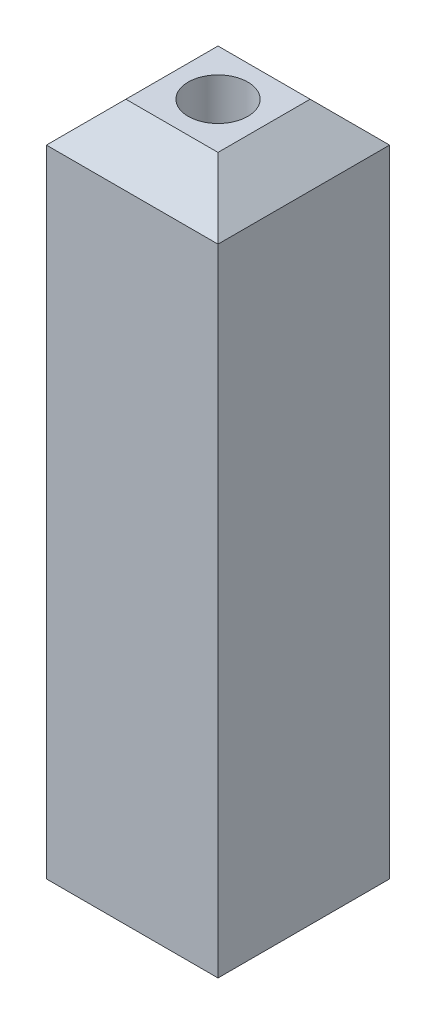
from build123d import *

# Parameters (mm, degrees)
SKETCH1_W                            = 54.864
SKETCH1_H                            = 54.864
BOSS_EXTRUDE2_DEPTH                  = 215.9
F_3_4_0_75_DIAMETER_HOLE1_D          = 19.05
F_3_4_0_75_DIAMETER_HOLE1_DEPTH      = 152.4
F_3_4_0_75_DIAMETER_HOLE1_TIP        = 5.723197396
F_13_64_0_20313_DIAMETER_HOLE1_D     = 5.159502
F_13_64_0_20313_DIAMETER_HOLE1_DEPTH = 152.4
F_13_64_0_20313_DIAMETER_HOLE1_TIP   = 1.550070783
F_3_4_0_75_DIAMETER_HOLE2_D          = 19.05
F_3_4_0_75_DIAMETER_HOLE2_DEPTH      = 42.545
F_3_4_0_75_DIAMETER_HOLE2_TIP        = 5.723197396
CHAMFER1_SIZE                        = 12.7


with BuildPart() as part:
    # Sketch1 → Boss-Extrude2 (new body)
    with BuildSketch(Plane(origin=(0, 0, 0), x_dir=(1, 0, 0), z_dir=(0, 1, 0))):
        Rectangle(SKETCH1_W, SKETCH1_H)
    extrude(amount=BOSS_EXTRUDE2_DEPTH)

    # 3/4 (0.75) Diameter Hole1
    with Locations(Plane.XZ):
        with Locations((0, 0)):
            Hole(F_3_4_0_75_DIAMETER_HOLE1_D / 2, depth=F_3_4_0_75_DIAMETER_HOLE1_DEPTH)
            with Locations((0, 0, -(F_3_4_0_75_DIAMETER_HOLE1_DEPTH + F_3_4_0_75_DIAMETER_HOLE1_TIP / 2))):  # 118° drill point
                Cone(0, F_3_4_0_75_DIAMETER_HOLE1_D / 2, F_3_4_0_75_DIAMETER_HOLE1_TIP, mode=Mode.SUBTRACT)

    # 13/64 (0.20313) Diameter Hole1
    with Locations(Plane.XZ):
        with Locations((-23.622, 23.622), (23.622, 23.622), (23.622, -23.622), (-23.622, -23.622)):
            Hole(F_13_64_0_20313_DIAMETER_HOLE1_D / 2, depth=F_13_64_0_20313_DIAMETER_HOLE1_DEPTH)
            with Locations((0, 0, -(F_13_64_0_20313_DIAMETER_HOLE1_DEPTH + F_13_64_0_20313_DIAMETER_HOLE1_TIP / 2))):  # 118° drill point
                Cone(0, F_13_64_0_20313_DIAMETER_HOLE1_D / 2, F_13_64_0_20313_DIAMETER_HOLE1_TIP, mode=Mode.SUBTRACT)

    # 3/4 (0.75) Diameter Hole2
    with Locations(Plane(origin=(0, 215.9, 0), x_dir=(-1, 0, 0), z_dir=(0, 1, 0))):
        with Locations((0, 0)):
            Hole(F_3_4_0_75_DIAMETER_HOLE2_D / 2, depth=F_3_4_0_75_DIAMETER_HOLE2_DEPTH)
            with Locations((0, 0, -(F_3_4_0_75_DIAMETER_HOLE2_DEPTH + F_3_4_0_75_DIAMETER_HOLE2_TIP / 2))):  # 118° drill point
                Cone(0, F_3_4_0_75_DIAMETER_HOLE2_D / 2, F_3_4_0_75_DIAMETER_HOLE2_TIP, mode=Mode.SUBTRACT)

    # Chamfer1
    chamfer1_edges = [part.edges().sort_by_distance(p)[0] for p in [
        (0, 215.9, 27.432),
        (-27.432, 215.9, 0),
        (0, 215.9, -27.432),
        (27.432, 215.9, 0),
    ]]
    chamfer(chamfer1_edges, length=CHAMFER1_SIZE)


solid = part.part
